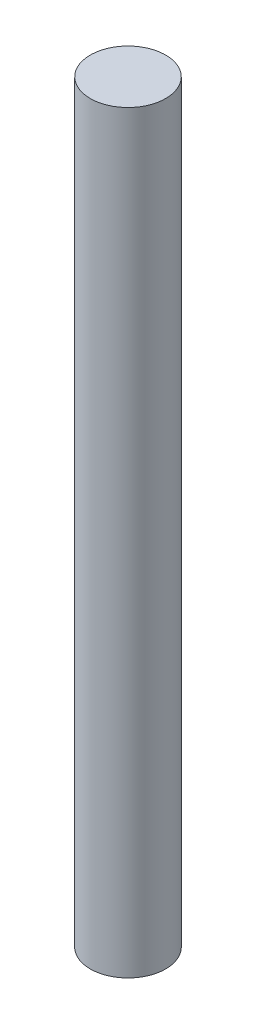
from build123d import *

# Parameters (mm, degrees)
SKETCH1_R           = 1.5
BOSS_EXTRUDE1_DEPTH = 15


with BuildPart() as part:
    # Sketch1 → Boss-Extrude1 (new body, symmetric)
    with BuildSketch(Plane(origin=(0, 0, 0), x_dir=(1, 0, 0), z_dir=(0, 1, 0))):
        Circle(SKETCH1_R)
    extrude(amount=BOSS_EXTRUDE1_DEPTH, both=True)


solid = part.part
